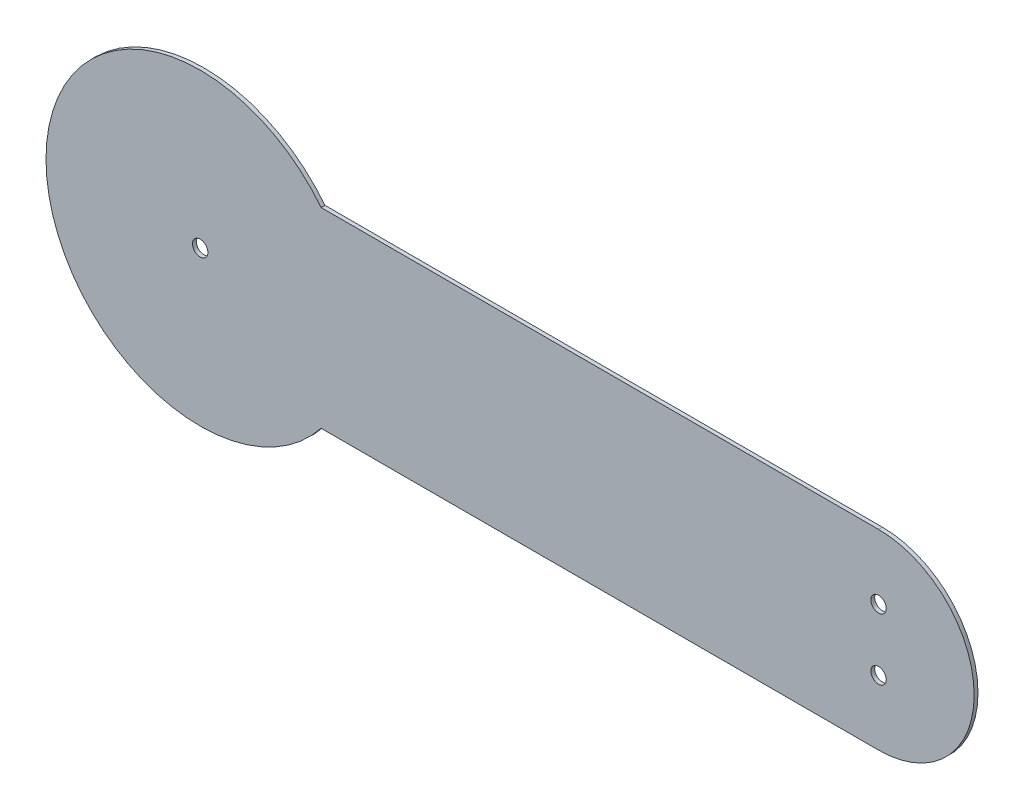
from build123d import *

# Parameters (mm, degrees)
SKETCH1_R           = 3.175
BOSS_EXTRUDE1_DEPTH = 1.5875


with BuildPart() as part:
    # Sketch1 → Boss-Extrude1 (new body)
    with BuildSketch(Plane.XY):
        with BuildLine():
            Line((279.4, -39.37), (49.822214925, -39.37))
            ThreePointArc((49.822214925, -39.37), (-63.5, 0), (49.822214925, 39.37))
            Line((49.822214925, 39.37), (279.4, 39.37))
            ThreePointArc((279.4, 39.37), (318.77, 0), (279.4, -39.37))
        make_face()
        Circle(SKETCH1_R, mode=Mode.SUBTRACT)
        with Locations((279.4, 12.7)):
            Circle(SKETCH1_R, mode=Mode.SUBTRACT)
        with Locations((279.4, -12.7)):
            Circle(SKETCH1_R, mode=Mode.SUBTRACT)
    extrude(amount=BOSS_EXTRUDE1_DEPTH)


solid = part.part
